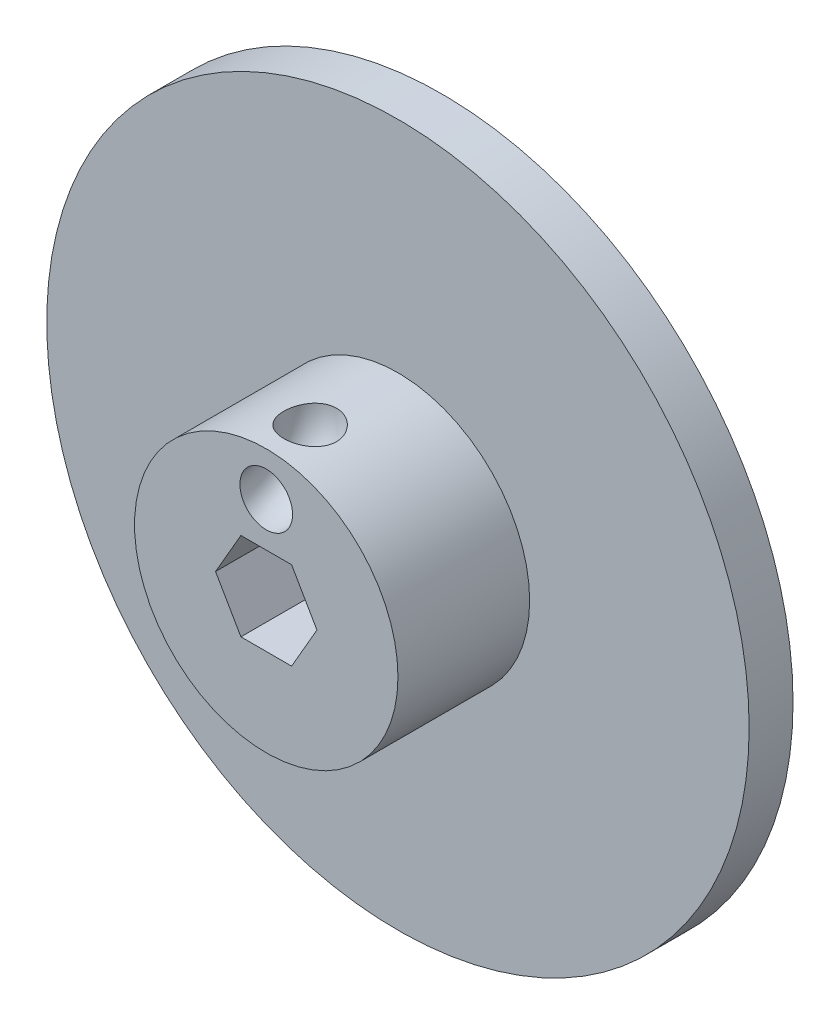
from build123d import *

# Parameters (mm, degrees)
SKETCH1_R           = 50.8
BOSS_EXTRUDE1_DEPTH = 6.35
SKETCH2_R           = 19.05
BOSS_EXTRUDE2_DEPTH = 19.05
CUT_EXTRUDE1_DEPTH  = 25.4
SKETCH4_R           = 3.81


with BuildPart() as part:
    # Sketch1 → Boss-Extrude1 (new body)
    with BuildSketch(Plane.XY):
        Circle(SKETCH1_R)
    extrude(amount=BOSS_EXTRUDE1_DEPTH)

    # Sketch2 → Boss-Extrude2 (add)
    with BuildSketch(Plane.XY.offset(6.35)):
        with Locations(Location((0, 0, 0), (0, 0, 180))):
            Circle(SKETCH2_R)
    extrude(amount=BOSS_EXTRUDE2_DEPTH)

    # Sketch3 → Cut-Extrude1 (cut)
    with BuildSketch(Plane.XY.offset(25.4)):
        Polygon((7.332348419, 0), (3.666174209, 6.35), (-3.666174209, 6.35), (-7.332348419, 0), (-3.666174209, -6.35), (3.666174209, -6.35), align=None)
    extrude(amount=-CUT_EXTRUDE1_DEPTH, mode=Mode.SUBTRACT)

    # Sketch4 → Cut-Revolve1 (revolve, cut)
    with BuildSketch(Plane(origin=(0, 19.05, 0), x_dir=(1, 0, 0), z_dir=(0, 1, 0)), mode=Mode.PRIVATE) as cut_revolve1_sk:
        with Locations((0, -19.05)):
            Circle(SKETCH4_R)
    revolve(cut_revolve1_sk.sketch.rotate(Axis((25.4, 19.05, 25.4), (-1, 0, 0)), 45.450641154), axis=Axis((25.4, 19.05, 25.4), (-1, 0, 0)), mode=Mode.SUBTRACT)


solid = part.part
